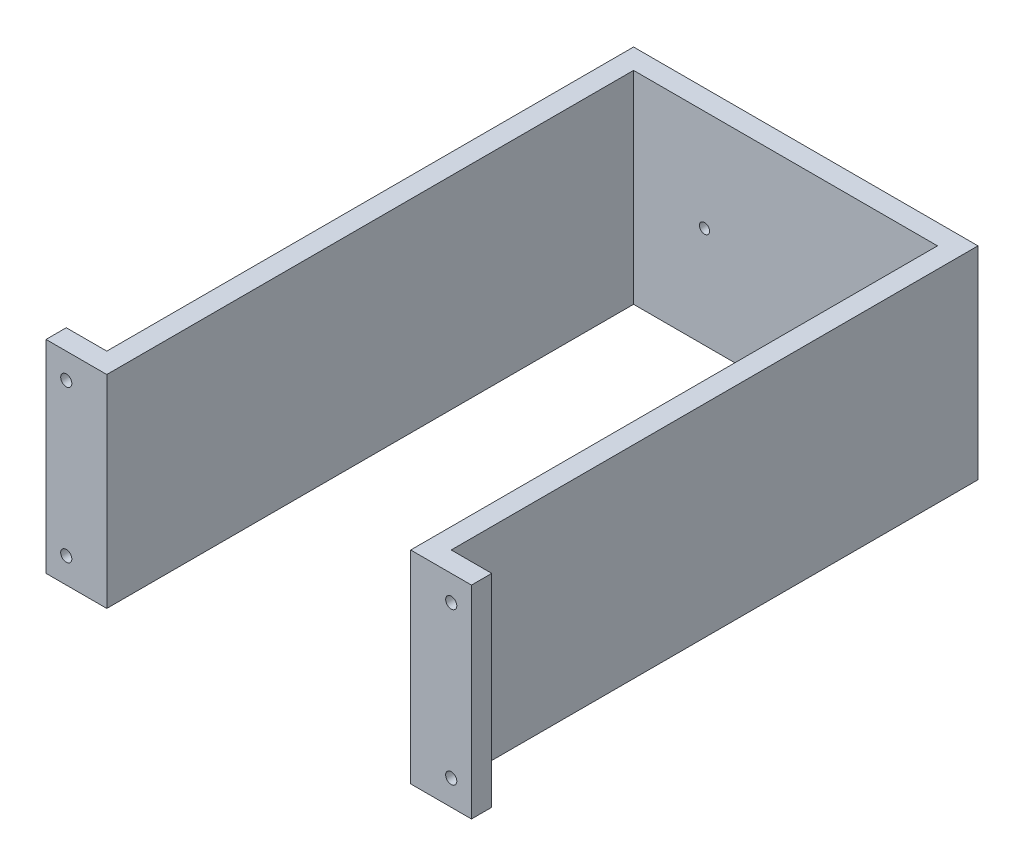
from build123d import *

# Parameters (mm, degrees)
BOSS_EXTRUDE1_DEPTH   = 100
M6_TAPPED_HOLE2_D     = 5
M6_TAPPED_HOLE2_DEPTH = 13.497848452
M6_TAPPED_HOLE2_TIP   = 1.502151548
SKETCH9_R             = 6
CUT_EXTRUDE2_DEPTH    = 2.6
SKETCH10_R            = 2.75
CUT_EXTRUDE3_DEPTH    = 11
SKETCH11_R            = 5.5
CUT_EXTRUDE4_DEPTH    = 5.5


with BuildPart() as part:
    # Sketch1 → Boss-Extrude1 (new body)
    with BuildSketch(Plane(origin=(0, 0, 0), x_dir=(1, 0, 0), z_dir=(0, 1, 0))):
        Polygon((0, 0), (30, 0), (30, 260), (180, 260), (180, 0), (210, 0), (210, 10), (190, 10), (190, 270), (20, 270), (20, 10), (0, 10), align=None)
    extrude(amount=BOSS_EXTRUDE1_DEPTH)

    # M6 Tapped Hole2
    with Locations(Plane(origin=(0, 0, -270), x_dir=(-1, 0, 0), z_dir=(0, 0, -1))):
        with Locations((-145, 50), (-65, 50)):
            Hole(M6_TAPPED_HOLE2_D / 2, depth=M6_TAPPED_HOLE2_DEPTH)
            with Locations((0, 0, -(M6_TAPPED_HOLE2_DEPTH + M6_TAPPED_HOLE2_TIP / 2))):  # 118° drill point
                Cone(0, M6_TAPPED_HOLE2_D / 2, M6_TAPPED_HOLE2_TIP, mode=Mode.SUBTRACT)

    # Sketch9 → Cut-Extrude2 (cut)
    with BuildSketch(Plane(origin=(0, 0, -270), x_dir=(-1, 0, 0), z_dir=(0, 0, -1))):
        with Locations((-145, 50)):
            Circle(SKETCH9_R)
        with Locations((-65, 50)):
            Circle(SKETCH9_R)
    extrude(amount=-CUT_EXTRUDE2_DEPTH, mode=Mode.SUBTRACT)

    # Sketch10 → Cut-Extrude3 (cut, through all)
    with BuildSketch(Plane(origin=(0, 0, -10), x_dir=(-1, 0, 0), z_dir=(0, 0, -1))):
        with Locations((-10, 87.5)):
            Circle(SKETCH10_R)
        with Locations((-10, 12.5)):
            Circle(SKETCH10_R)
        with Locations((-200, 12.5)):
            Circle(SKETCH10_R)
        with Locations((-200, 87.5)):
            Circle(SKETCH10_R)
    extrude(amount=-CUT_EXTRUDE3_DEPTH, mode=Mode.SUBTRACT)

    # Sketch11 → Cut-Extrude4 (cut)
    with BuildSketch(Plane(origin=(0, 0, -10), x_dir=(-1, 0, 0), z_dir=(0, 0, -1))):
        with Locations((-10, 87.5)):
            Circle(SKETCH11_R)
        with Locations((-10, 12.5)):
            Circle(SKETCH11_R)
        with Locations((-200, 12.5)):
            Circle(SKETCH11_R)
        with Locations((-200, 87.5)):
            Circle(SKETCH11_R)
    extrude(amount=-CUT_EXTRUDE4_DEPTH, mode=Mode.SUBTRACT)


solid = part.part
